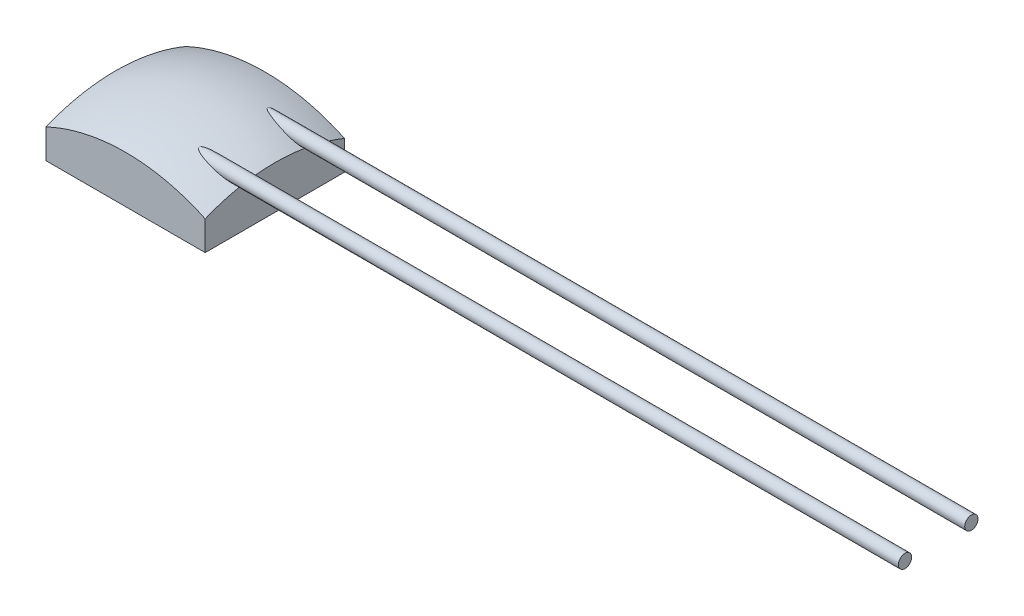
from build123d import *

# Parameters (mm, degrees)
SKETCH_3_OUTSIDE_W   = 6.506
SKETCH_3_OUTSIDE_H   = 6.506
SKETCH_3_OUTSIDE_W_2 = 2.4
SKETCH_3_OUTSIDE_H_2 = 2.1
CUT_EXTRUDE_1_DEPTH  = 1.9
SKETCH_4_R           = 0.1
EXTRUDE_2_DEPTH      = 10
EXTRUDE_2_DEPTH_BACK = 1


with BuildPart() as part:
    # Эскиз2 → Повернуть1 (revolve)
    with BuildSketch(Plane.XY):
        with BuildLine():
            Line((0, 0), (1.75, 0))
            Line((1.75, 0), (1.75, 0.336698586))
            ThreePointArc((1.75, 0.336698586), (0.919212772, 0.755704445), (0, 0.9))
            Line((0, 0.9), (0, 0))
        make_face()
    revolve(axis=Axis((0, 0, 0), (0, 1, 0)))

    # Эскиз3 outside → Вырез-Вытянуть1 (cut, through all)
    with BuildSketch(Plane.XZ):
        Rectangle(SKETCH_3_OUTSIDE_W, SKETCH_3_OUTSIDE_H)
        Rectangle(SKETCH_3_OUTSIDE_W_2, SKETCH_3_OUTSIDE_H_2, mode=Mode.SUBTRACT)
    extrude(amount=-CUT_EXTRUDE_1_DEPTH, mode=Mode.SUBTRACT)

    # Эскиз4 → Бобышка-Вытянуть2 (add, two sides)
    with BuildSketch(Plane(origin=(1.2, 0, 0), x_dir=(0, 0, -1), z_dir=(1, 0, 0))) as extrude_2_sk:
        with Locations((-0.5, 0.7)):
            Circle(SKETCH_4_R)
        with Locations((0.5, 0.7)):
            Circle(SKETCH_4_R)
    extrude(amount=EXTRUDE_2_DEPTH)
    extrude(extrude_2_sk.sketch, amount=-EXTRUDE_2_DEPTH_BACK)


solid = part.part
